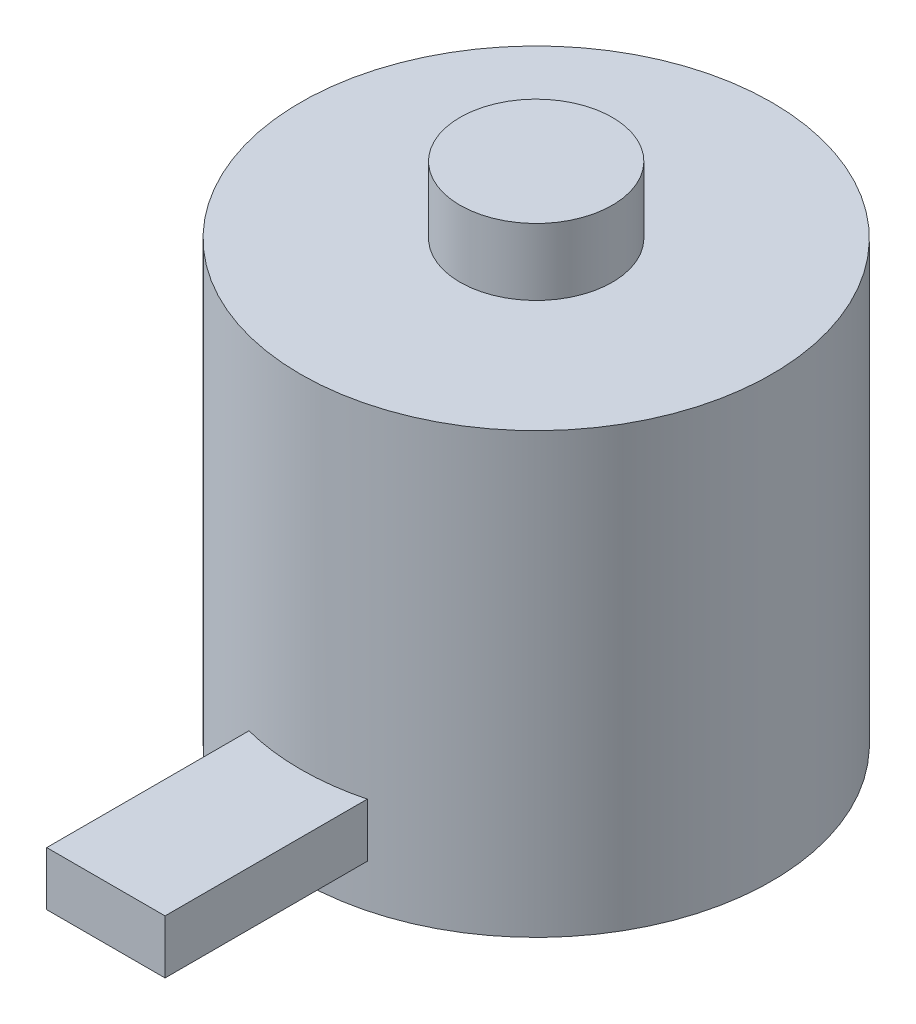
from build123d import *

# Parameters (mm, degrees)
SKETCH1_R           = 13.9065
BOSS_EXTRUDE1_DEPTH = 14.9225
SKETCH2_R           = 13.9065
SKETCH2_R_2         = 4.4958
CUT_EXTRUDE1_DEPTH  = 3.937
SKETCH3_W           = 6.985
SKETCH3_H           = 3.175
BOSS_EXTRUDE2_DEPTH = 25.4
SKETCH4_R           = 1.5
CUT_EXTRUDE2_DEPTH  = 12.7


with BuildPart() as part:
    # Sketch1 → Boss-Extrude1 (new body, symmetric)
    with BuildSketch(Plane(origin=(0, 0, 0), x_dir=(1, 0, 0), z_dir=(0, 1, 0))):
        Circle(SKETCH1_R)
    extrude(amount=BOSS_EXTRUDE1_DEPTH, both=True)

    # Sketch2 → Cut-Extrude1 (cut)
    with BuildSketch(Plane(origin=(0, 14.9225, 0), x_dir=(1, 0, 0), z_dir=(0, 1, 0))):
        Circle(SKETCH2_R)
        Circle(SKETCH2_R_2, mode=Mode.SUBTRACT)
    extrude(amount=-CUT_EXTRUDE1_DEPTH, mode=Mode.SUBTRACT)

    # Sketch3 → Boss-Extrude2 (add)
    with BuildSketch(Plane.XY):
        with Locations((0, -10.795)):
            Rectangle(SKETCH3_W, SKETCH3_H)
    extrude(amount=BOSS_EXTRUDE2_DEPTH)

    # Sketch4 → Cut-Extrude2 (cut)
    with BuildSketch(Plane.XZ.offset(14.9225)):
        with Locations((-5.656854249, 5.656854249)):
            Circle(SKETCH4_R)
        with Locations((6.717514421, 6.717514421)):
            Circle(SKETCH4_R)
        with Locations((5.656854249, -5.656854249)):
            Circle(SKETCH4_R)
        with Locations((-6.717514421, -6.717514421)):
            Circle(SKETCH4_R)
    extrude(amount=-CUT_EXTRUDE2_DEPTH, mode=Mode.SUBTRACT)


solid = part.part
